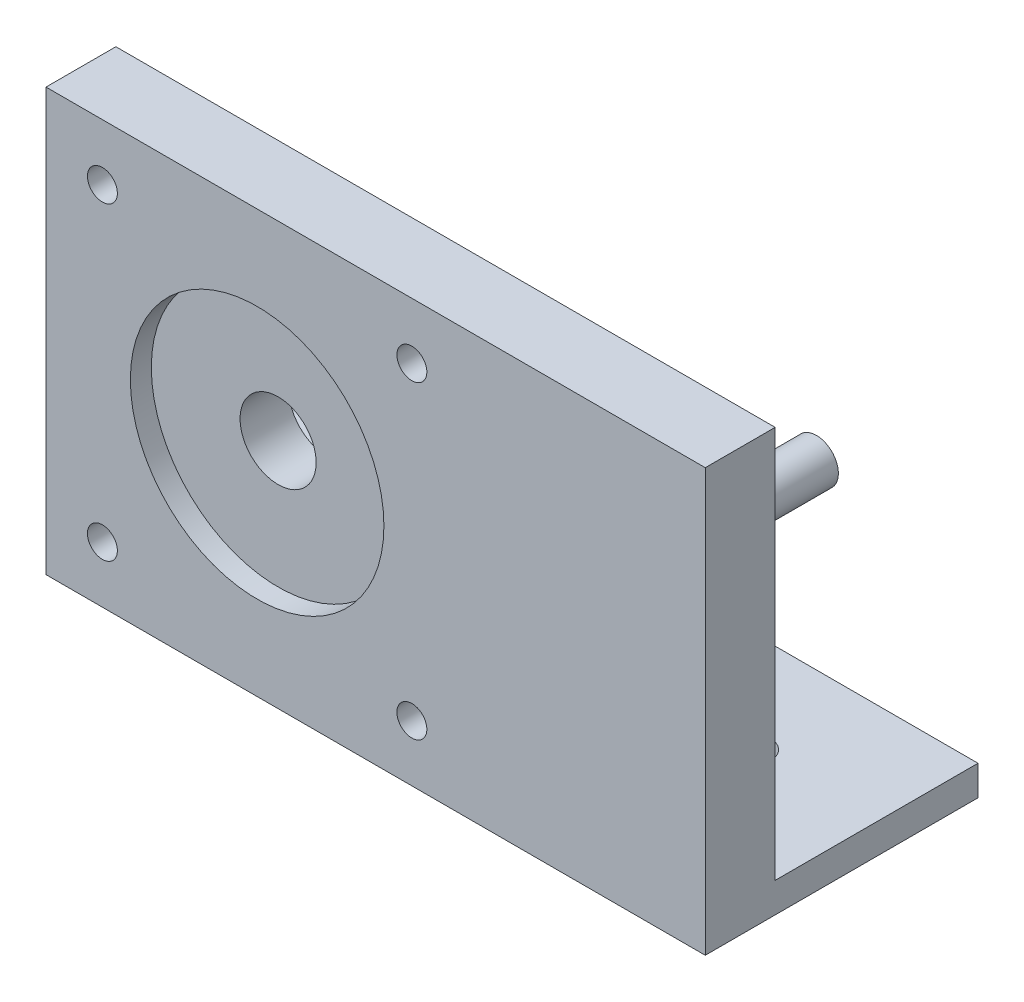
from build123d import *

# Parameters (mm, degrees)
BOSS_EXTRUDE1_DEPTH    = 66.04
SKETCH3_R              = 12.7
CUT_EXTRUDE1_DEPTH     = 2.1
SKETCH2_R              = 1.5
SKETCH2_R_2            = 3.81
CUT_EXTRUDE2_DEPTH     = 8
SKETCH4_R              = 2.2
BOSS_EXTRUDE2_DEPTH    = 20.32
SKETCH6_W              = 12.1468
SKETCH6_H              = 12
CUT_EXTRUDE3_DEPTH     = 4
SKETCH7_R              = 2.8
CUT_EXTRUDE4_DEPTH     = 1.27
SKETCH8_R              = 1.925
M4_BOTTOM_SCREWS_DEPTH = 4


with BuildPart() as part:
    # Sketch1 → Boss-Extrude1 (new body)
    with BuildSketch(Plane(origin=(0, 0, 0), x_dir=(0, 0, -1), z_dir=(1, 0, 0))):
        Polygon((7, 3), (27.32, 3), (27.32, 0), (2.660377358, 0), (0, 0), (0, 42.3), (7, 42.3), align=None)
    extrude(amount=BOSS_EXTRUDE1_DEPTH)

    # Sketch3 → Cut-Extrude1 (cut)
    with BuildSketch(Plane.XY):
        with Locations((21.15, 21.15)):
            Circle(SKETCH3_R)
    extrude(amount=-CUT_EXTRUDE1_DEPTH, mode=Mode.SUBTRACT)

    # Sketch2 → Cut-Extrude2 (cut, through all)
    with BuildSketch(Plane(origin=(0, 0, -7), x_dir=(-1, 0, 0), z_dir=(0, 0, -1))):
        with Locations((-5.65, 36.65)):
            Circle(SKETCH2_R)
        with Locations((-5.65, 5.65)):
            Circle(SKETCH2_R)
        with Locations((-36.65, 36.65)):
            Circle(SKETCH2_R)
        with Locations((-36.65, 5.65)):
            Circle(SKETCH2_R)
        with Locations((-21.15, 21.15)):
            Circle(SKETCH2_R_2)
    extrude(amount=-CUT_EXTRUDE2_DEPTH, mode=Mode.SUBTRACT)

    # Sketch4 → Boss-Extrude2 (add)
    with BuildSketch(Plane(origin=(0, 0, -7), x_dir=(-1, 0, 0), z_dir=(0, 0, -1))):
        with Locations((-49.852, 21.15)):
            Circle(SKETCH4_R)
    extrude(amount=BOSS_EXTRUDE2_DEPTH)

    # Sketch6 → Cut-Extrude3 (cut, through all)
    with BuildSketch(Plane(origin=(0, 3, 0), x_dir=(1, 0, 0), z_dir=(0, 1, 0))):
        with Locations((35.4276, 13)):
            Rectangle(SKETCH6_W, SKETCH6_H)
    extrude(amount=-CUT_EXTRUDE3_DEPTH, mode=Mode.SUBTRACT)

    # Sketch7 → Cut-Extrude4 (cut)
    with BuildSketch(Plane(origin=(0, 0, -7), x_dir=(-1, 0, 0), z_dir=(0, 0, -1))):
        with Locations((-36.65, 36.65)):
            Circle(SKETCH7_R)
        with Locations((-36.65, 5.65)):
            Circle(SKETCH7_R)
        with Locations((-5.65, 5.65)):
            Circle(SKETCH7_R)
        with Locations((-5.65, 36.65)):
            Circle(SKETCH7_R)
    extrude(amount=-CUT_EXTRUDE4_DEPTH, mode=Mode.SUBTRACT)

    # Sketch8 → M4 bottom screws (cut, through all)
    with BuildSketch(Plane(origin=(0, 3, 0), x_dir=(1, 0, 0), z_dir=(0, 1, 0))):
        with Locations((20.3542, 17.16)):
            Circle(SKETCH8_R)
        with Locations((53.501, 17.16)):
            Circle(SKETCH8_R)
    extrude(amount=-M4_BOTTOM_SCREWS_DEPTH, mode=Mode.SUBTRACT)


solid = part.part
